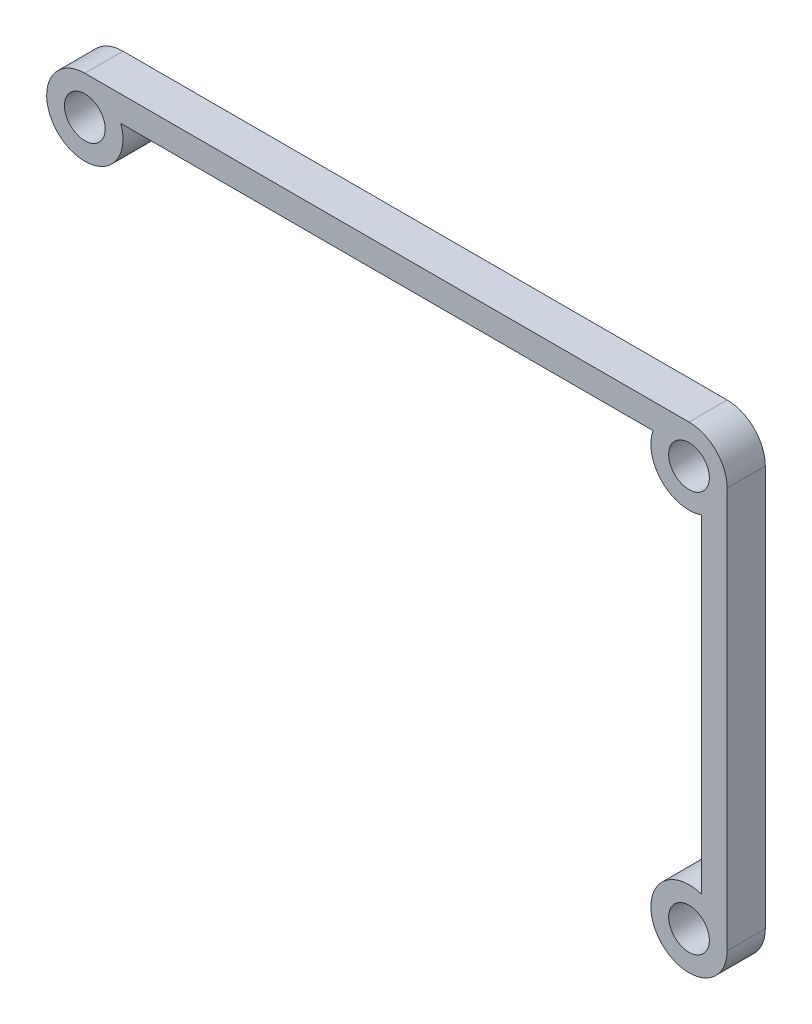
from build123d import *

# Parameters (mm, degrees)
ESBO_O1_R                = 1.6
RESSALTO_EXTRUS_O1_DEPTH = 3


with BuildPart() as part:
    # Esboço1 → Ressalto-extrusão1 (new body)
    with BuildSketch(Plane.XY):
        with BuildLine():
            Line((26.75, 15.75), (26.75, -15.75))
            ThreePointArc((26.75, -15.75), (21.300510257, -17.482050808), (24.75, -12.921572875))
            Line((24.75, -12.921572875), (24.75, 12.921572875))
            ThreePointArc((24.75, 12.921572875), (21.628679656, 13.628679656), (20.921572875, 16.75))
            Line((20.921572875, 16.75), (-20.921572875, 16.75))
            ThreePointArc((-20.921572875, 16.75), (-25.482050808, 13.300510257), (-23.75, 18.75))
            Line((-23.75, 18.75), (23.75, 18.75))
            ThreePointArc((23.75, 18.75), (25.871320344, 17.871320344), (26.75, 15.75))
        make_face()
        with Locations((-23.75, 15.75)):
            Circle(ESBO_O1_R, mode=Mode.SUBTRACT)
        with Locations((23.75, 15.75)):
            Circle(ESBO_O1_R, mode=Mode.SUBTRACT)
        with Locations((23.75, -15.75)):
            Circle(ESBO_O1_R, mode=Mode.SUBTRACT)
    extrude(amount=RESSALTO_EXTRUS_O1_DEPTH)


solid = part.part
